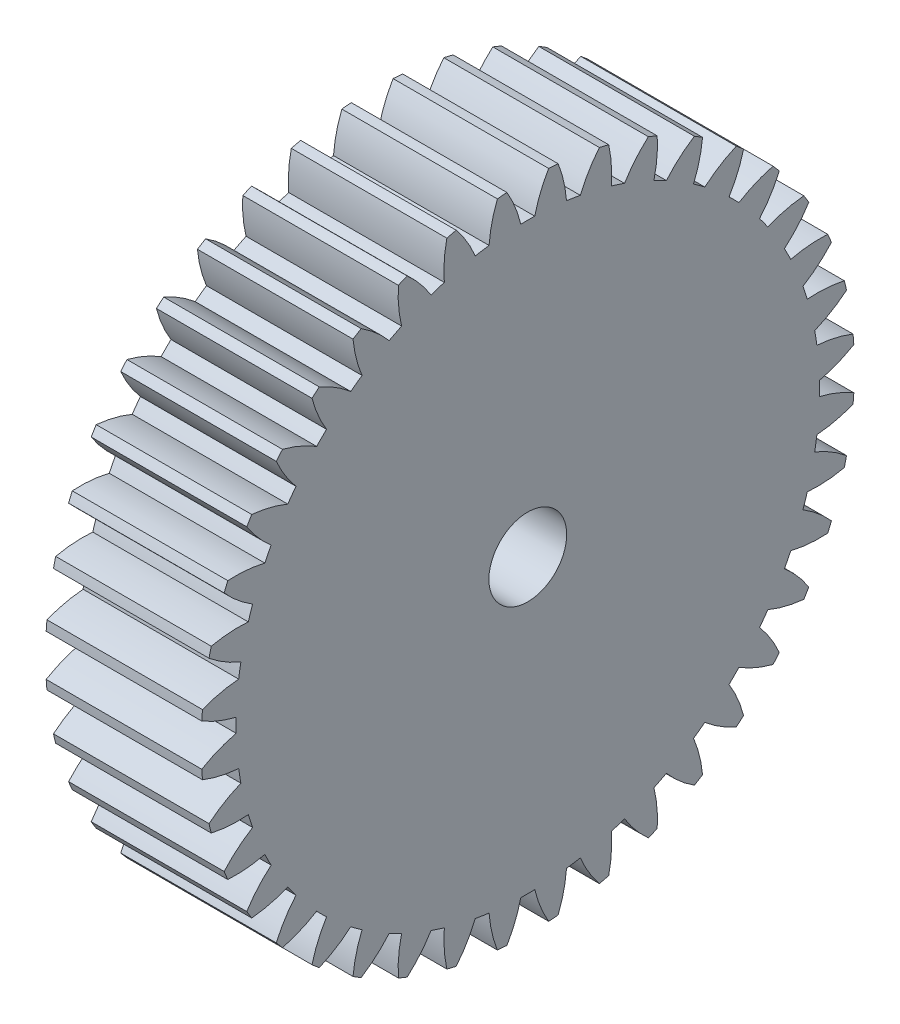
from build123d import *

# Parameters (mm, degrees)
BASPROSKE_W     = 10
BASPROSKE_H     = 21
TOOTHCUT_DEPTH  = 32.336879232
TEETHCUTS_COUNT = 40
TEETHCUTS_ANGLE = 351
BORSKE_R        = 2.5
BORE_DEPTH      = 50.0000508


with BuildPart() as part:
    # BasProSke → Base-Revolve (revolve)
    with BuildSketch(Plane(origin=(0, 0, 0), x_dir=(1, 0, 0), z_dir=(0, 1, 0)), mode=Mode.PRIVATE) as base_revolve_sk:
        with Locations((5, 10.5)):
            Rectangle(BASPROSKE_W, BASPROSKE_H)
    revolve(base_revolve_sk.sketch.rotate(Axis((-10, 0, 0), (1, 0, 0)), 180), axis=Axis((-10, 0, 0), (1, 0, 0)))

    # TooCutSke → ToothCut (cut, through all)
    with BuildSketch(Plane(origin=(0, 0, 0), x_dir=(0, 0, -1), z_dir=(1, 0, 0))):
        with BuildLine():
            ThreePointArc((0.448673268, 18.74363074), (0, 18.749), (-0.448673268, 18.74363074))
            ThreePointArc((-0.448673268, 18.74363074), (-0.816786816, 19.89705013), (-1.354745081, 20.981708961))
            ThreePointArc((-1.354745081, 20.981708961), (0, 21.0254), (1.354745081, 20.981708961))
            ThreePointArc((1.354745081, 20.981708961), (0.816786816, 19.89705013), (0.448673268, 18.74363074))
        make_face()
    toothcut = extrude(amount=TOOTHCUT_DEPTH, mode=Mode.SUBTRACT)

    # TeethCuts: ToothCut ×40 about axis
    teethcuts_axis = Axis((-10, 0, 0), (1, 0, 0))
    for i in range(1, TEETHCUTS_COUNT):
        add(toothcut.rotate(teethcuts_axis, i * TEETHCUTS_ANGLE / (TEETHCUTS_COUNT - 1)), mode=Mode.SUBTRACT)

    # BorSke → Bore (cut, symmetric)
    with BuildSketch(Plane(origin=(0, 0, 0), x_dir=(0, 0, -1), z_dir=(1, 0, 0))):
        with Locations(Location((0, 0, 0), (0, 0, 180))):
            Circle(BORSKE_R)
    extrude(amount=BORE_DEPTH, both=True, mode=Mode.SUBTRACT)


solid = part.part
